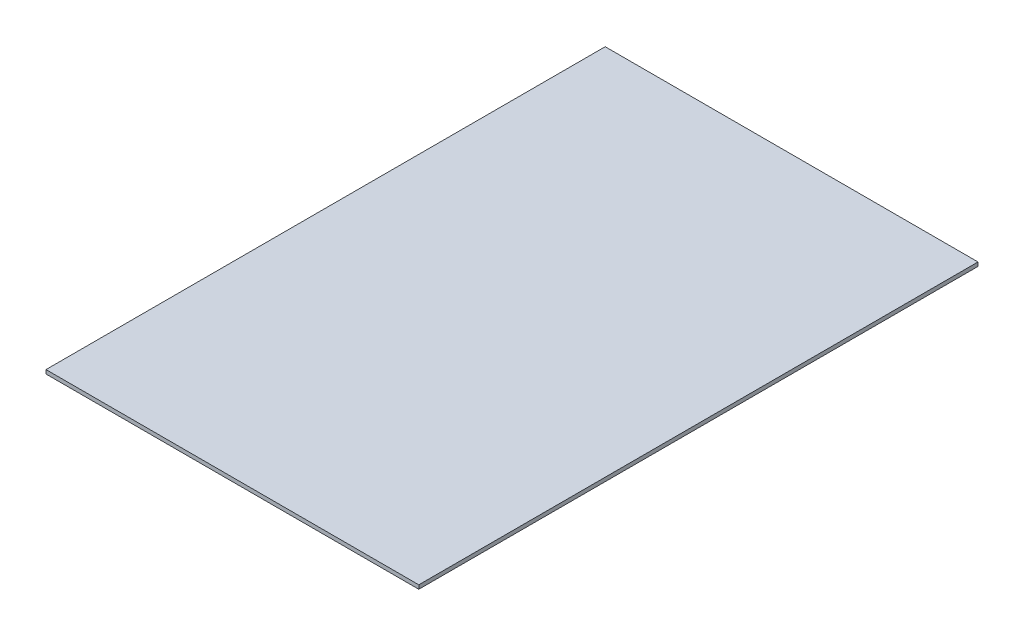
from build123d import *

# Parameters (mm, degrees)
SKETCH1_W           = 609.6
SKETCH1_H           = 914.4
BOSS_EXTRUDE1_DEPTH = 6.35


with BuildPart() as part:
    # Sketch1 → Boss-Extrude1 (new body)
    with BuildSketch(Plane(origin=(0, 0, 0), x_dir=(1, 0, 0), z_dir=(0, 1, 0))):
        Rectangle(SKETCH1_W, SKETCH1_H)
    extrude(amount=BOSS_EXTRUDE1_DEPTH)


solid = part.part
